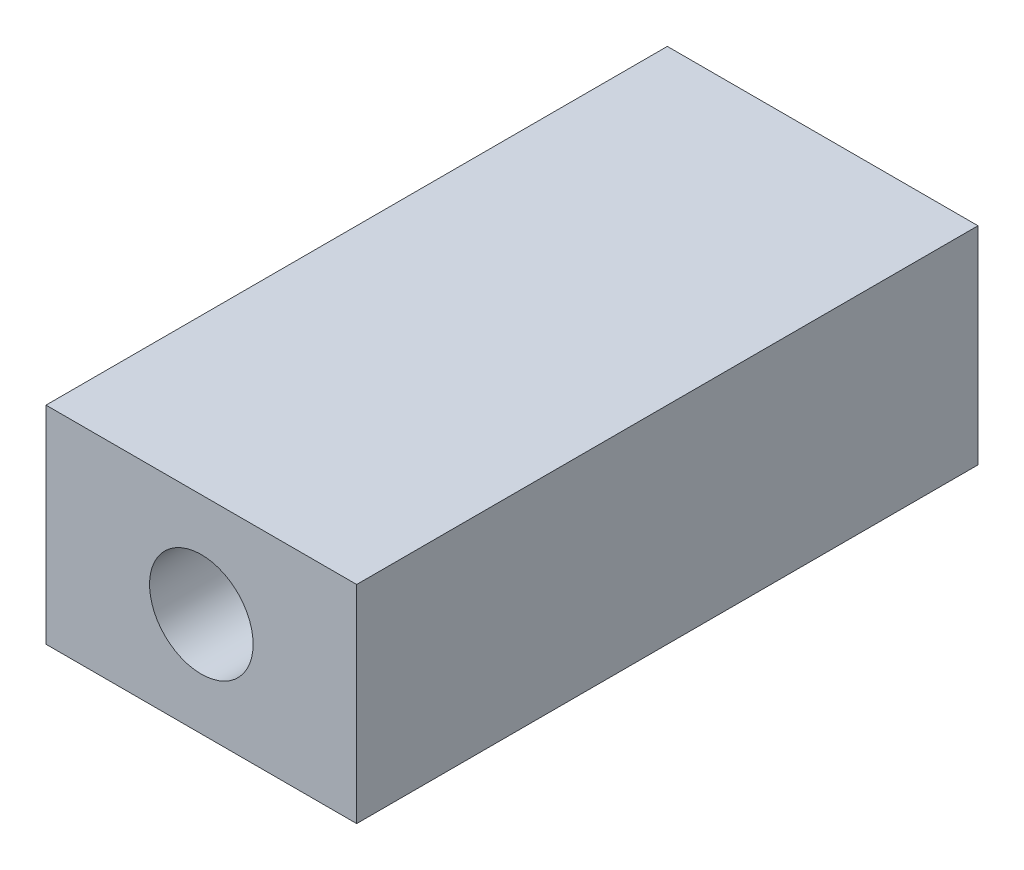
from build123d import *

# Parameters (mm, degrees)
ESQUISSE1_W             = 6
ESQUISSE1_H             = 4
ESQUISSE1_R             = 0.5
BOSS_EXTRU_1_DEPTH      = 12
ESQUISSE2_R             = 1
ENL_V_MAT_EXTRU_1_DEPTH = 6


with BuildPart() as part:
    # Esquisse1 → Boss.-Extru.1 (new body)
    with BuildSketch(Plane.XY):
        with Locations((0.349498461, -0.412280702)):
            Rectangle(ESQUISSE1_W, ESQUISSE1_H)
        with Locations((0.349498461, -0.412280702)):
            Circle(ESQUISSE1_R, mode=Mode.SUBTRACT)
    extrude(amount=BOSS_EXTRU_1_DEPTH)

    # Esquisse2 → Enlèv. mat.-Extru.1 (cut)
    with BuildSketch(Plane.XY.offset(12)):
        with Locations((0.349498461, -0.412280702)):
            Circle(ESQUISSE2_R)
    extrude(amount=-ENL_V_MAT_EXTRU_1_DEPTH, mode=Mode.SUBTRACT)


solid = part.part
